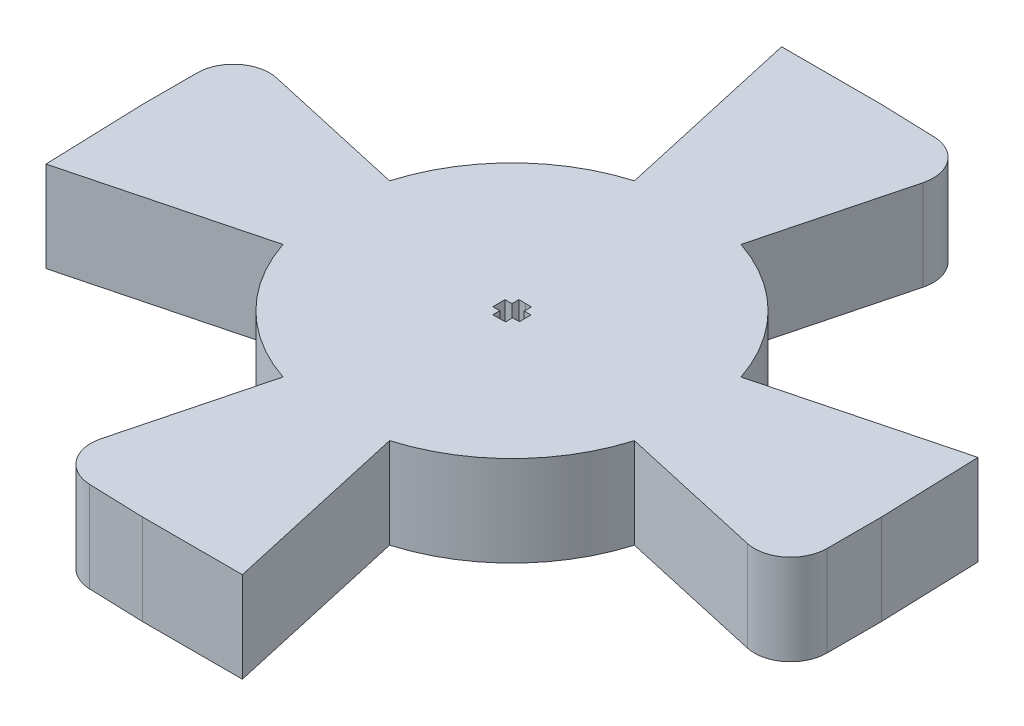
from build123d import *

# Parameters (mm, degrees)
BOSS_EXTRUDE1_DEPTH = 5
FILLET1_R           = 2


with BuildPart() as part:
    # Sketch1 → Boss-Extrude1 (new body)
    with BuildSketch(Plane(origin=(0, 0, 0), x_dir=(1, 0, 0), z_dir=(0, 1, 0))):
        with BuildLine():
            Line((5.177710586, -20.063712518), (2.831257578, -9.590827937))
            ThreePointArc((2.831257578, -9.590827937), (7.071067812, -7.071067812), (9.590827937, -2.831257578))
            Line((9.590827937, -2.831257578), (20.063712518, -5.177710586))
            Line((20.063712518, -5.177710586), (20.063712518, 0.338076022))
            Line((20.063712518, 0.338076022), (19.877881915, 5.850731362))
            Line((19.877881915, 5.850731362), (9.489996307, 3.152771812))
            ThreePointArc((9.489996307, 3.152771812), (7.071067812, 7.071067812), (3.152771812, 9.489996307))
            Line((3.152771812, 9.489996307), (5.850731362, 19.877881915))
            Line((5.850731362, 19.877881915), (0.338076022, 20.063712518))
            Line((0.338076022, 20.063712518), (-5.177710586, 20.063712518))
            Line((-5.177710586, 20.063712518), (-2.831257578, 9.590827937))
            ThreePointArc((-2.831257578, 9.590827937), (-7.071067812, 7.071067812), (-9.590827937, 2.831257578))
            Line((-9.590827937, 2.831257578), (-20.063712518, 5.177710586))
            Line((-20.063712518, 5.177710586), (-20.063712518, -0.338076022))
            Line((-20.063712518, -0.338076022), (-19.877881915, -5.850731362))
            Line((-19.877881915, -5.850731362), (-9.489996307, -3.152771812))
            ThreePointArc((-9.489996307, -3.152771812), (-7.071067812, -7.071067812), (-3.152771812, -9.489996307))
            Line((-3.152771812, -9.489996307), (-5.850731362, -19.877881915))
            Line((-5.850731362, -19.877881915), (-0.338076022, -20.063712518))
            Line((-0.338076022, -20.063712518), (5.177710586, -20.063712518))
        make_face()
        Polygon((-0.338076022, -0.721880139), (-0.338076022, -0.338076022), (-0.721880139, -0.338076022), (-0.721880139, 0.338076022), (-0.338076022, 0.338076022), (-0.338076022, 0.721880139), (0.012163769, 0.721880139), (0.362204732, 0.710080322), (0.34927411, 0.326494088), (0.732860345, 0.313563466), (0.722290178, 0), (0.732860345, -0.313563466), (0.34927411, -0.326494088), (0.362204732, -0.710080322), (0.012163769, -0.721880139), align=None, mode=Mode.SUBTRACT)
    extrude(amount=BOSS_EXTRUDE1_DEPTH)

    # Fillet1
    fillet1_edges = [part.edges().sort_by_distance(p)[0] for p in [
        (20.063712518, 2.5, 5.177710586),
        (-5.850731362, 2.5, 19.877881915),
        (-20.063712518, 2.5, -5.177710586),
        (5.850731362, 2.5, -19.877881915),
    ]]
    fillet(fillet1_edges, radius=FILLET1_R)


solid = part.part
